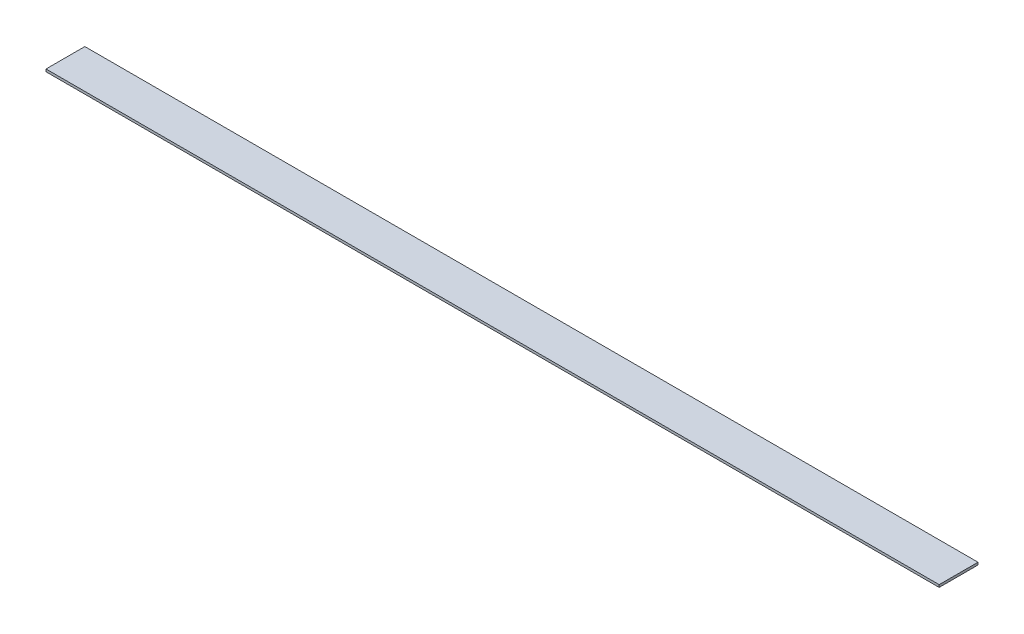
from build123d import *

# Parameters (mm, degrees)
SKETCH1_W           = 1168.4
SKETCH1_H           = 50.8
BOSS_EXTRUDE1_DEPTH = 3.175


with BuildPart() as part:
    # Sketch1 → Boss-Extrude1 (new body)
    with BuildSketch(Plane(origin=(0, 0, 0), x_dir=(1, 0, 0), z_dir=(0, 1, 0))):
        Rectangle(SKETCH1_W, SKETCH1_H)
    extrude(amount=BOSS_EXTRUDE1_DEPTH)


solid = part.part
